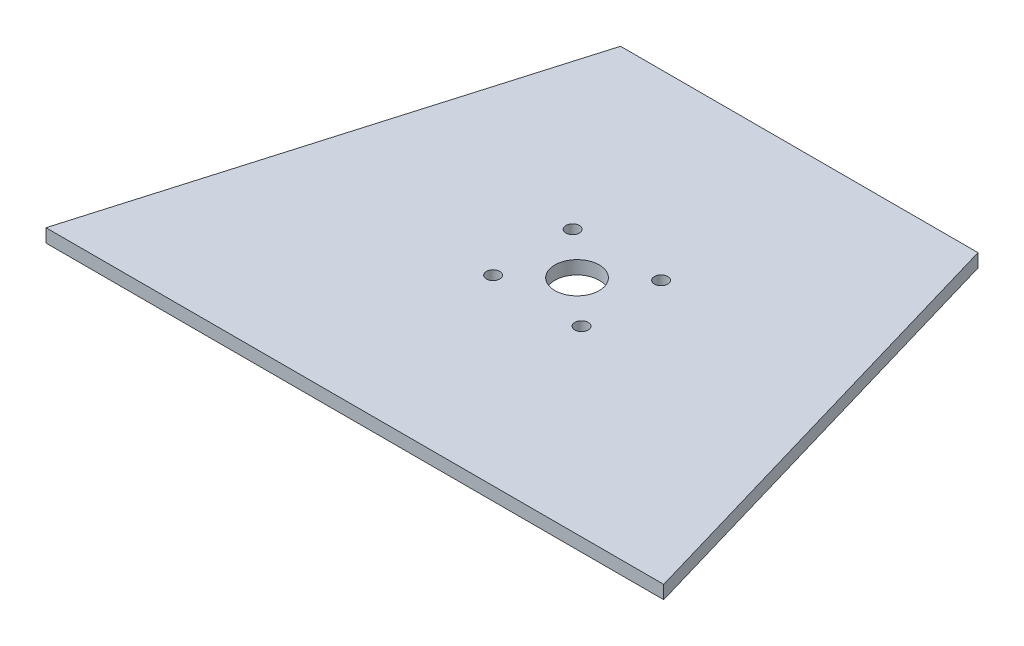
from build123d import *

# Parameters (mm, degrees)
BOSS_EXTRUDE1_DEPTH        = 3
F_10_0MM_DOWEL_HOLE1_D     = 10
F_10_0MM_DOWEL_HOLE1_DEPTH = 3
F_3_0MM_DOWEL_HOLE1_D      = 3
F_3_0MM_DOWEL_HOLE1_DEPTH  = 3


with BuildPart() as part:
    # Sketch1 → Boss-Extrude1 (new body)
    with BuildSketch(Plane(origin=(0, 0, 0), x_dir=(1, 0, 0), z_dir=(0, 1, 0))):
        Polygon((0, 0), (139, 0), (109.720058283, 100), (29.279941717, 100), align=None)
    extrude(amount=BOSS_EXTRUDE1_DEPTH)

    # Ø10.0mm Dowel Hole1
    with Locations(Plane(origin=(0, 0, 0), x_dir=(-1, 0, 0), z_dir=(0, -1, 0))):
        with Locations((-69.5, 50)):
            Hole(F_10_0MM_DOWEL_HOLE1_D / 2, depth=F_10_0MM_DOWEL_HOLE1_DEPTH)

    # Ø3.0mm Dowel Hole1
    with Locations(Plane(origin=(0, 0, 0), x_dir=(-1, 0, 0), z_dir=(0, -1, 0))):
        with Locations((-59.55, 41.05), (-79.45, 41.05), (-79.45, 58.95), (-59.55, 58.95)):
            Hole(F_3_0MM_DOWEL_HOLE1_D / 2, depth=F_3_0MM_DOWEL_HOLE1_DEPTH)


solid = part.part
